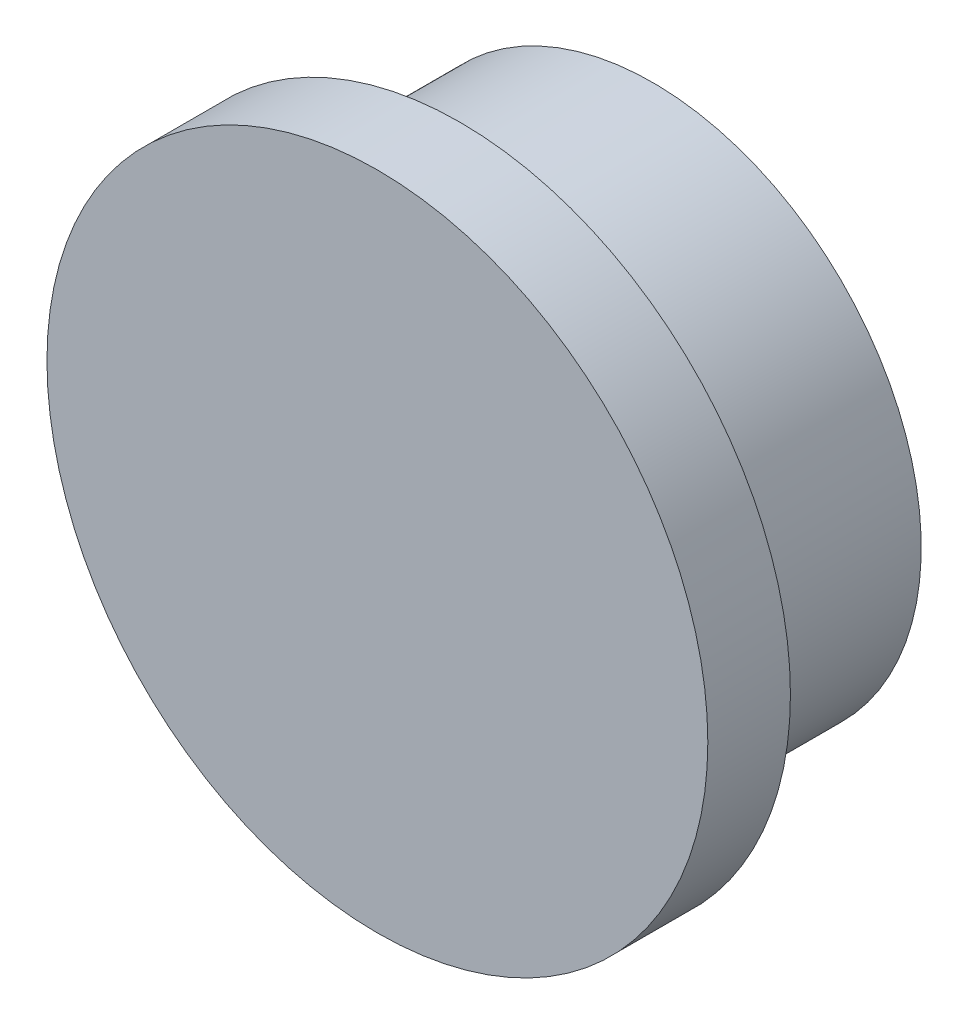
from build123d import *

# Parameters (mm, degrees)
SKETCH1_R           = 12
BOSS_EXTRUDE1_DEPTH = 3
SKETCH2_R           = 9.75
BOSS_EXTRUDE2_DEPTH = 7
SKETCH3_R           = 2.35
CUT_EXTRUDE1_DEPTH  = 5


with BuildPart() as part:
    # Sketch1 → Boss-Extrude1 (new body)
    with BuildSketch(Plane.XY):
        with Locations((-127.992538975, 40.103259291)):
            Circle(SKETCH1_R)
    extrude(amount=BOSS_EXTRUDE1_DEPTH)

    # Sketch2 → Boss-Extrude2 (add)
    with BuildSketch(Plane(origin=(0, 0, 0), x_dir=(-1, 0, 0), z_dir=(0, 0, -1))):
        with Locations((127.992538975, 40.103259291)):
            Circle(SKETCH2_R)
    extrude(amount=BOSS_EXTRUDE2_DEPTH)

    # Sketch3 → Cut-Extrude1 (cut)
    with BuildSketch(Plane(origin=(0, 0, -7), x_dir=(-1, 0, 0), z_dir=(0, 0, -1))):
        with Locations((127.992538975, 40.103259291)):
            Circle(SKETCH3_R)
    extrude(amount=-CUT_EXTRUDE1_DEPTH, mode=Mode.SUBTRACT)


solid = part.part
